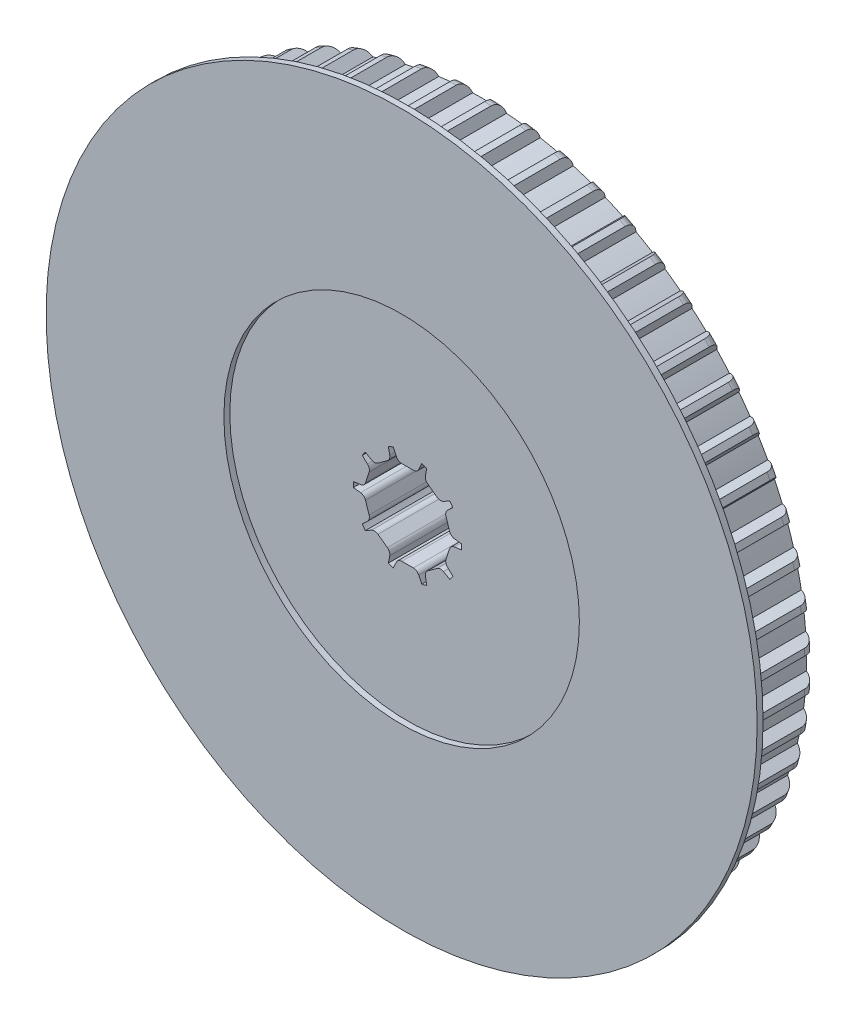
from build123d import *

# Parameters (mm, degrees)
SCHNITT_LINEAR_AUSTRAGEN1_DEPTH = 8.1
KREISMUSTER1_COUNT              = 60
AUFSATZ_LINEAR_AUSTRAGEN1_DEPTH = 7.1
VERRUNDUNG1_R                   = 0.5
KREISMUSTER2_COUNT              = 10
VERRUNDUNG1_OF_KREISMUSTER2_R   = 0.5
VERRUNDUNG2_R                   = 0.5


with BuildPart() as part:
    # Skizze1 → Rotation1 (revolve)
    with BuildSketch(Plane(origin=(0, 0, 0), x_dir=(0, 0, -1), z_dir=(1, 0, 0))):
        with BuildLine():
            Line((0, 4.57), (0, 28.24))
            Line((0, 28.24), (5.3, 28.24))
            ThreePointArc((5.3, 28.24), (6.007106781, 27.947106781), (6.3, 27.24))
            Line((6.3, 27.24), (6.3, 6.1))
            Line((6.3, 6.1), (7.1, 6.1))
            Line((7.1, 6.1), (7.1, 4.57))
            Line((7.1, 4.57), (0, 4.57))
        make_face()
    revolve(axis=Axis((0, 0, 33.276923077), (0, 0, -1)))

    # Skizze2 → Schnitt-Linear austragen1 (cut, through all)
    with BuildSketch(Plane.XY):
        with BuildLine():
            Line((0.80304446, 27.363218827), (1.2, 28.21449273))
            ThreePointArc((1.2, 28.21449273), (0, 28.24), (-1.2, 28.21449273))
            Line((-1.2, 28.21449273), (-0.80304446, 27.363218827))
            ThreePointArc((-0.80304446, 27.363218827), (0, 27.375), (0.80304446, 27.363218827))
        make_face()
    schnitt_linear_austragen1 = extrude(amount=-SCHNITT_LINEAR_AUSTRAGEN1_DEPTH, mode=Mode.SUBTRACT)

    # Kreismuster1: Schnitt-Linear austragen1 ×60 about axis
    kreismuster1_axis = Axis((0, 0, 0), (0, 0, 1))
    for i in range(1, KREISMUSTER1_COUNT):
        add(schnitt_linear_austragen1.rotate(kreismuster1_axis, i * 360 / KREISMUSTER1_COUNT), mode=Mode.SUBTRACT)

    # Skizze3 → Aufsatz-Linear austragen1 (add)
    with BuildSketch(Plane.XY):
        with BuildLine():
            Line((0.808470756, 3.57), (1.2, 4.409637173))
            ThreePointArc((1.2, 4.409637173), (0, 4.57), (-1.2, 4.409637173))
            Line((-1.2, 4.409637173), (-0.808470756, 3.57))
            Line((-0.808470756, 3.57), (0.808470756, 3.57))
        make_face()
    aufsatz_linear_austragen1 = extrude(amount=-AUFSATZ_LINEAR_AUSTRAGEN1_DEPTH)

    # Verrundung1
    verrundung1_edges = [part.edges().sort_by_distance(p)[0] for p in [
        (0.808470756, 3.57, -3.55),
        (-0.808470756, 3.57, -3.55),
    ]]
    fillet(verrundung1_edges, radius=VERRUNDUNG1_R)

    # Kreismuster2: Aufsatz-Linear austragen1 ×10 about axis
    kreismuster2_axis = Axis((0, 0, 0), (0, 0, 1))
    for i in range(1, KREISMUSTER2_COUNT):
        add(aufsatz_linear_austragen1.rotate(kreismuster2_axis, i * 360 / KREISMUSTER2_COUNT))

    # Verrundung1 of Kreismuster2
    verrundung1_of_kreismuster2_edges = [part.edges().sort_by_distance(p)[0] for p in [
        (-1.44432677, 3.363397857, -3.55),
        (-2.752459932, 2.412983483, -3.55),
        (-3.14544056, 1.872092051, -3.55),
        (-3.645102966, 0.334289289, -3.55),
        (-3.645102966, -0.334289289, -3.55),
        (-3.14544056, -1.872092051, -3.55),
        (-2.752459932, -2.412983483, -3.55),
        (-1.44432677, -3.363397857, -3.55),
        (-0.808470756, -3.57, -3.55),
        (0.808470756, -3.57, -3.55),
        (1.44432677, -3.363397857, -3.55),
        (2.752459932, -2.412983483, -3.55),
        (3.14544056, -1.872092051, -3.55),
        (3.645102966, -0.334289289, -3.55),
        (3.645102966, 0.334289289, -3.55),
        (3.14544056, 1.872092051, -3.55),
        (2.752459932, 2.412983483, -3.55),
        (1.44432677, 3.363397857, -3.55),
    ]]
    fillet(verrundung1_of_kreismuster2_edges, radius=VERRUNDUNG1_OF_KREISMUSTER2_R)

    # Skizze4 → Rotation2 (revolve)
    with BuildSketch(Plane(origin=(0, 0, 0), x_dir=(0, 0, -1), z_dir=(1, 0, 0))):
        with BuildLine():
            Line((0, 15), (-0.5, 15))
            Line((-0.5, 15), (-0.5, 30))
            Line((-0.5, 30), (0, 30))
            Line((0, 30), (0, 28.5))
            Line((0, 28.5), (0.653553391, 27.846446609))
            ThreePointArc((0.653553391, 27.846446609), (0.761939766, 27.684234935), (0.8, 27.492893219))
            Line((0.8, 27.492893219), (0.8, 26))
            Line((0.8, 26), (0, 26))
            Line((0, 26), (0, 15))
        make_face()
    revolve(axis=Axis((0, 0, 12.748207041), (0, 0, -1)))

    # Skizze5 → Schnitt-Rotation1 (revolve, cut)
    with BuildSketch(Plane(origin=(0, 0, 0), x_dir=(0, 0, -1), z_dir=(1, 0, 0))):
        Polygon((7.1, 4.2), (6.3, 5), (6.3, 6.1), (7.1, 6.1), align=None)
    revolve(axis=Axis((0, 0, -13.523679913), (0, 0, 1)), mode=Mode.SUBTRACT)

    # Verrundung2
    verrundung2_edges = [part.edges().sort_by_distance(p)[0] for p in [
        (2.46869806, 3.397871376, -7.1),
        (3.994437368, 1.297871376, -7.1),
        (3.994437368, -1.297871376, -7.1),
        (2.46869806, -3.397871376, -7.1),
        (0, -4.2, -7.1),
        (-2.46869806, -3.397871376, -7.1),
        (-3.994437368, -1.297871376, -7.1),
        (-3.994437368, 1.297871376, -7.1),
        (-2.46869806, 3.397871376, -7.1),
        (0.524669304, 4.167099965, -7.1),
    ]]
    fillet(verrundung2_edges, radius=VERRUNDUNG2_R)


solid = part.part
